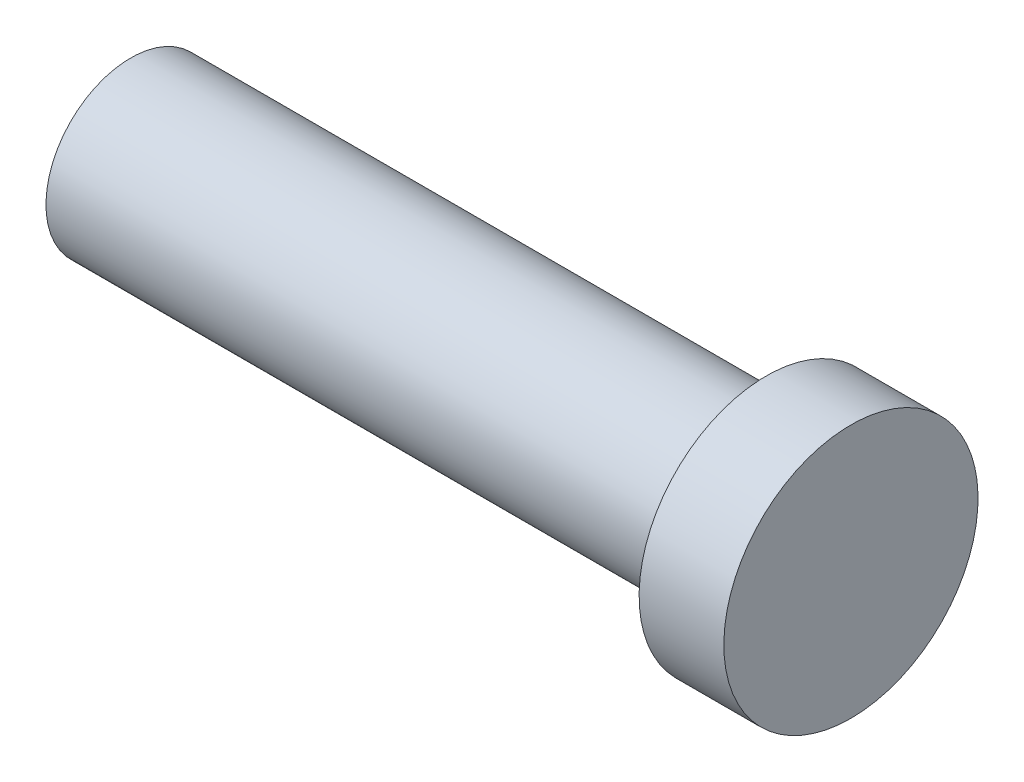
from build123d import *


with BuildPart() as part:
    # Sketch1 → Revolve1 (revolve)
    with BuildSketch(Plane.XY):
        Polygon((-4.296296296, 0), (0, 0), (0, 2), (0, 3), (-2, 3), (-2, 2), (-17, 2), (-17, 0), align=None)
    revolve(axis=Axis((-17, 0, 0), (1, 0, 0)))


solid = part.part
